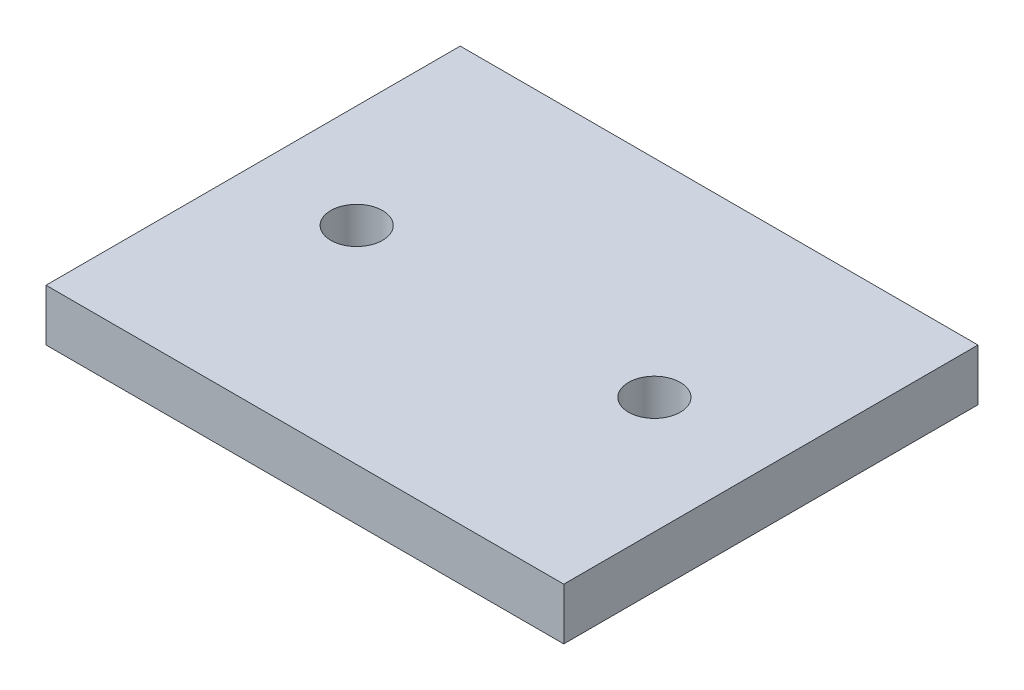
from build123d import *

# Parameters (mm, degrees)
SKETCH2_W           = 127
SKETCH2_H           = 101.6
SKETCH2_R           = 6.35
BOSS_EXTRUDE1_DEPTH = 12.7


with BuildPart() as part:
    # Sketch2 → Boss-Extrude1 (new body)
    with BuildSketch(Plane(origin=(0, 0, 0), x_dir=(1, 0, 0), z_dir=(0, 1, 0))):
        with Locations((63.5, -50.8)):
            Rectangle(SKETCH2_W, SKETCH2_H)
        with Locations((25.4, -50.8)):
            Circle(SKETCH2_R, mode=Mode.SUBTRACT)
        with Locations((98.425, -50.8)):
            Circle(SKETCH2_R, mode=Mode.SUBTRACT)
    extrude(amount=BOSS_EXTRUDE1_DEPTH)


solid = part.part
